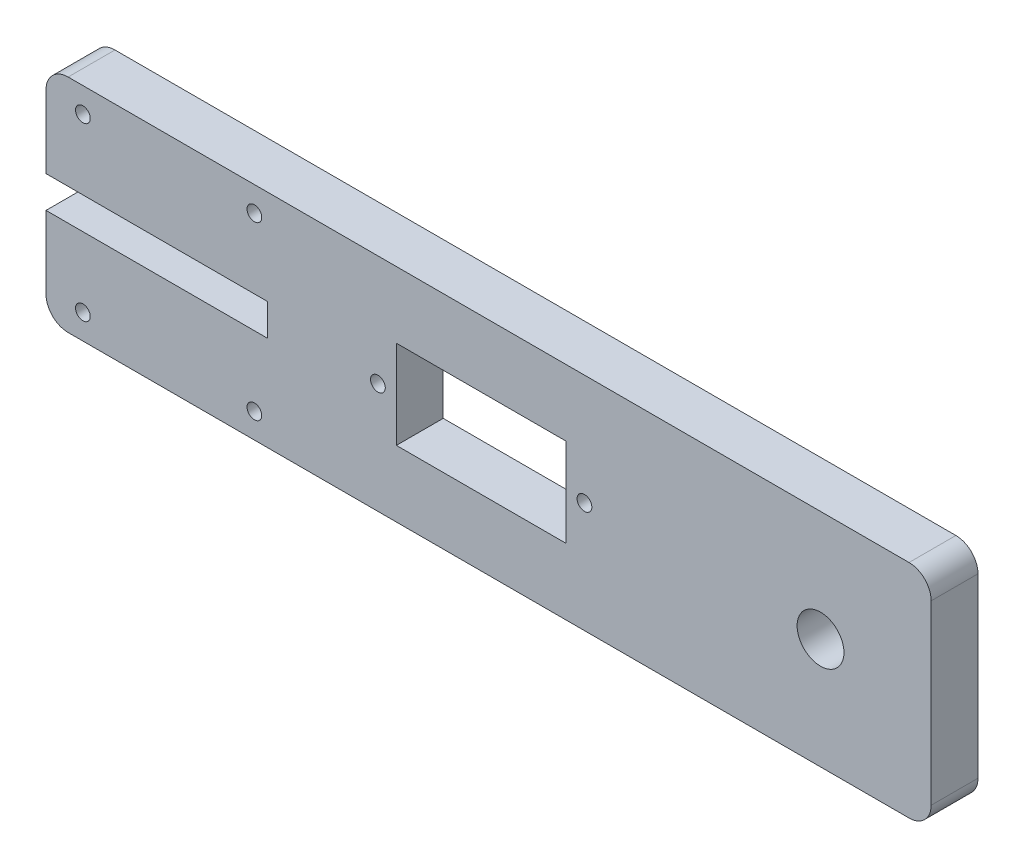
from build123d import *

# Parameters (mm, degrees)
MAIN_SHAPE_DEPTH                              = 6.35
FILLET1_R                                     = 3
ELBOW_X_MOUNT_HOLES_D                         = 1.9939
ELBOW_X_MOUNT_HOLES_DEPTH                     = 7.67
ELBOW_X_MOUNT_HOLES_TIP                       = 0.599027994
SKETCH6_W                                     = 23
SKETCH6_H                                     = 12
CUTOUT_FOR_WRIST_SERVO_DEPTH                  = 7.35
WRIST_SERVO_MOUNTING_HOLES_D                  = 1.9939
F_1_4_0_25_DIAMETER_HOLE_FOR_WRIST_DOWE_D     = 6.35
F_1_4_0_25_DIAMETER_HOLE_FOR_WRIST_DOWE_DEPTH = 18
F_1_4_0_25_DIAMETER_HOLE_FOR_WRIST_DOWE_TIP   = 1.907732465


with BuildPart() as part:
    # Sketch1 → main shape (new body)
    with BuildSketch(Plane.XY):
        Polygon((0, 17.159), (0, 30), (120, 30), (120, 0), (0, 0), (0, 12.841), (30, 12.841), (30, 17.159), align=None)
    extrude(amount=MAIN_SHAPE_DEPTH)

    # Fillet1
    fillet1_edges = [part.edges().sort_by_distance(p)[0] for p in [
        (0, 30, 3.175),
        (120, 30, 3.175),
        (120, 0, 3.175),
        (0, 0, 3.175),
    ]]
    fillet(fillet1_edges, radius=FILLET1_R)

    # elbow X mount holes
    with Locations(Plane.XY.offset(6.35)):
        with Locations((5, 26.625), (28.25, 26.625), (28.25, 3.375), (5, 3.375)):
            Hole(ELBOW_X_MOUNT_HOLES_D / 2, depth=ELBOW_X_MOUNT_HOLES_DEPTH)
            with Locations((0, 0, -(ELBOW_X_MOUNT_HOLES_DEPTH + ELBOW_X_MOUNT_HOLES_TIP / 2))):  # 118° drill point
                Cone(0, ELBOW_X_MOUNT_HOLES_D / 2, ELBOW_X_MOUNT_HOLES_TIP, mode=Mode.SUBTRACT)

    # Sketch6 → cutout for wrist servo (cut, through all)
    with BuildSketch(Plane.XY.offset(6.35)):
        with Locations((59, 15)):
            Rectangle(SKETCH6_W, SKETCH6_H)
    extrude(amount=-CUTOUT_FOR_WRIST_SERVO_DEPTH, mode=Mode.SUBTRACT)

    # wrist servo mounting holes (through all)
    with Locations(Plane.XY.offset(6.35)):
        with Locations((45, 15), (73, 15)):
            Hole(WRIST_SERVO_MOUNTING_HOLES_D / 2)

    # 1/4 (0.25) Diameter Hole (for wrist dowel)
    with Locations(Plane.XY.offset(6.35)):
        with Locations((105, 15)):
            Hole(F_1_4_0_25_DIAMETER_HOLE_FOR_WRIST_DOWE_D / 2, depth=F_1_4_0_25_DIAMETER_HOLE_FOR_WRIST_DOWE_DEPTH)
            with Locations((0, 0, -(F_1_4_0_25_DIAMETER_HOLE_FOR_WRIST_DOWE_DEPTH + F_1_4_0_25_DIAMETER_HOLE_FOR_WRIST_DOWE_TIP / 2))):  # 118° drill point
                Cone(0, F_1_4_0_25_DIAMETER_HOLE_FOR_WRIST_DOWE_D / 2, F_1_4_0_25_DIAMETER_HOLE_FOR_WRIST_DOWE_TIP, mode=Mode.SUBTRACT)


solid = part.part
